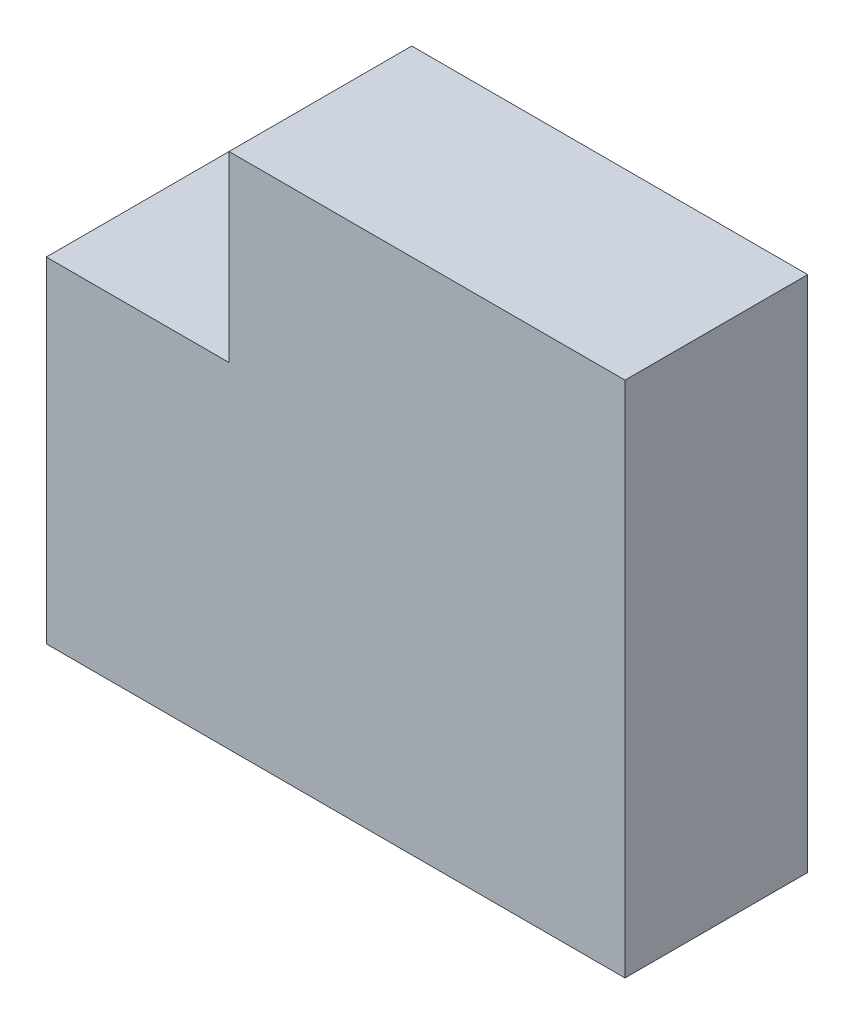
from build123d import *

# Parameters (mm, degrees)
RESSALTO_EXTRUS_O1_DEPTH = 6


with BuildPart() as part:
    # Esboço1 → Ressalto-extrusão1 (new body)
    with BuildSketch(Plane.XY):
        Polygon((0, 11), (0, 0), (19, 0), (19, 17), (6, 17), (6, 11), align=None)
    extrude(amount=RESSALTO_EXTRUS_O1_DEPTH)


solid = part.part
